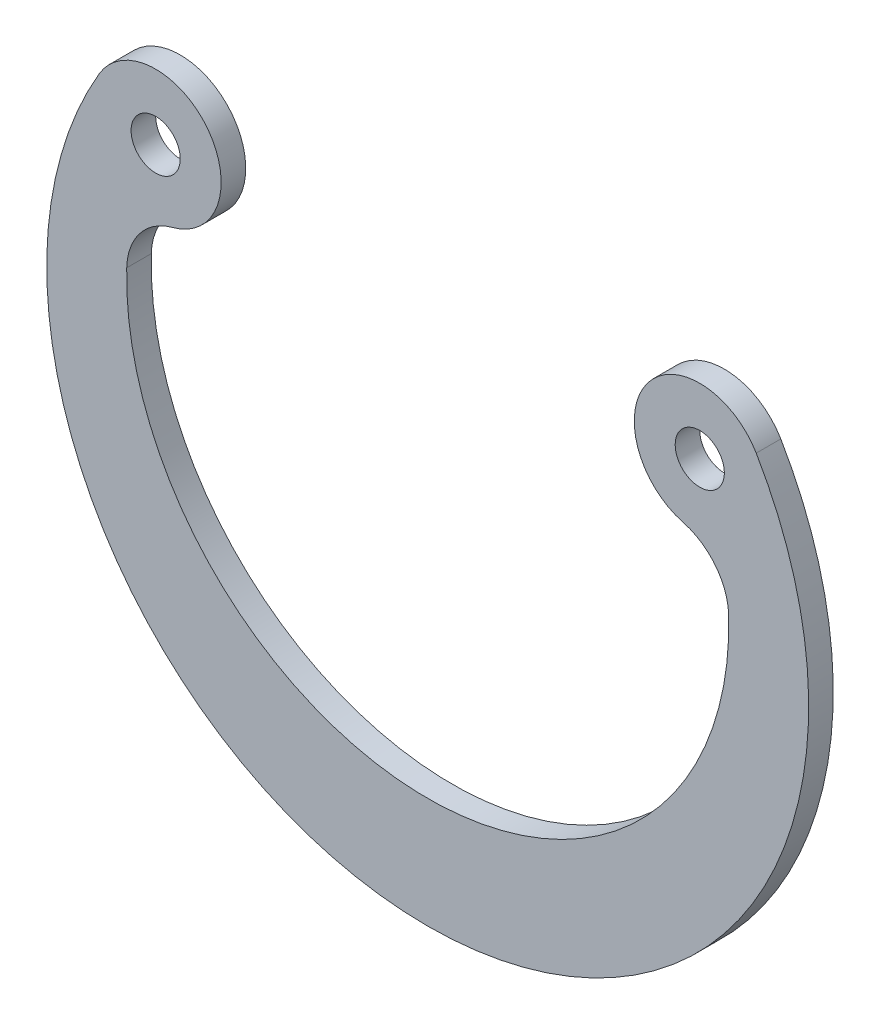
from build123d import *

# Parameters (mm, degrees)
SKETCH_1_R      = 1
EXTRUDE_1_DEPTH = 1


with BuildPart() as part:
    # Эскиз1 → Бобышка-Вытянуть1 (new body)
    with BuildSketch(Plane.XY):
        with BuildLine():
            ThreePointArc((-13.365556031, 7.849325575), (0, -15.5), (13.365556031, 7.849325575))
            ThreePointArc((13.365556031, 7.849325575), (8.94560833, 8.110945689), (10.386242309, 3.924186023))
            ThreePointArc((10.386242309, 3.924186023), (11.7073461, 3.058360422), (12.245730412, 1.573398627))
            ThreePointArc((12.245730412, 1.573398627), (0, -11), (-12.245730412, 1.573398627))
            ThreePointArc((-12.245730412, 1.573398627), (-11.7073461, 3.058360422), (-10.386242309, 3.924186023))
            ThreePointArc((-10.386242309, 3.924186023), (-8.94560833, 8.110945689), (-13.365556031, 7.849325575))
        make_face()
        with Locations((-11.067971811, 6.5)):
            Circle(SKETCH_1_R, mode=Mode.SUBTRACT)
        with Locations((11.067971811, 6.5)):
            Circle(SKETCH_1_R, mode=Mode.SUBTRACT)
    extrude(amount=-EXTRUDE_1_DEPTH)


solid = part.part
